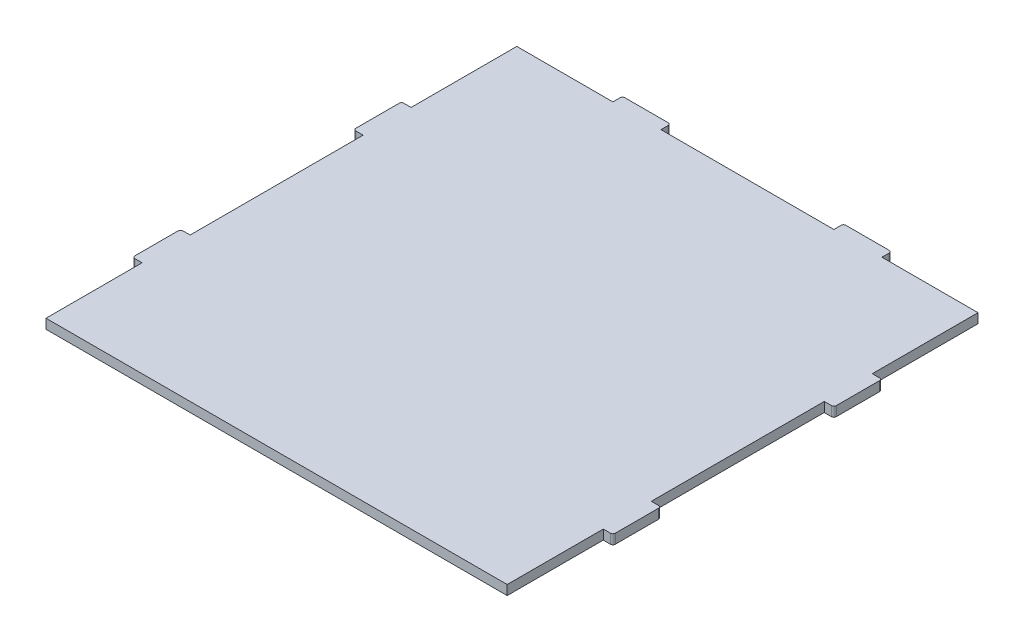
from build123d import *

# Parameters (mm, degrees)
SKETCH1_W           = 96
SKETCH1_H           = 2
BOSS_EXTRUDE1_DEPTH = 98
SKETCH2_W           = 10
SKETCH2_H           = 2
BOSS_EXTRUDE2_DEPTH = 2
SKETCH3_W           = 10
SKETCH3_H           = 2
BOSS_EXTRUDE3_DEPTH = 2
SKETCH4_W           = 10
SKETCH4_H           = 2
BOSS_EXTRUDE4_DEPTH = 2
FILLET1_R           = 0.5


with BuildPart() as part:
    # Sketch1 → Boss-Extrude1 (new body)
    with BuildSketch(Plane.XY):
        with Locations((0, 49)):
            Rectangle(SKETCH1_W, SKETCH1_H)
    extrude(amount=BOSS_EXTRUDE1_DEPTH)

    # Sketch2 → Boss-Extrude2 (add)
    with BuildSketch(Plane(origin=(0, 0, 0), x_dir=(-1, 0, 0), z_dir=(0, 0, -1))):
        with Locations((-23, 49)):
            Rectangle(SKETCH2_W, SKETCH2_H)
    boss_extrude2 = extrude(amount=BOSS_EXTRUDE2_DEPTH)

    # Mirror1: Boss-Extrude2 across plane
    add(boss_extrude2.mirror(Plane(origin=(0, 0, 0), x_dir=(0, 0, 1), z_dir=(1, 0, 0))))

    # Sketch3 → Boss-Extrude3 (add)
    with BuildSketch(Plane.ZY.offset(48)):
        with Locations((73, 49)):
            Rectangle(SKETCH3_W, SKETCH3_H)
    boss_extrude3 = extrude(amount=BOSS_EXTRUDE3_DEPTH)

    # Mirror2: Boss-Extrude3 across plane
    add(boss_extrude3.mirror(Plane.XY.offset(50)))

    # Sketch4 → Boss-Extrude4 (add)
    with BuildSketch(Plane(origin=(48, 0, 0), x_dir=(0, 0, -1), z_dir=(1, 0, 0))):
        with Locations((-73, 49)):
            Rectangle(SKETCH4_W, SKETCH4_H)
    boss_extrude4 = extrude(amount=BOSS_EXTRUDE4_DEPTH)

    # Mirror3: Boss-Extrude4 across plane
    add(boss_extrude4.mirror(Plane.XY.offset(50)))

    # Fillet1
    fillet1_edges = [part.edges().sort_by_distance(p)[0] for p in [
        (18, 49, -2),
        (28, 49, -2),
        (-28, 49, -2),
        (-18, 49, -2),
        (-50, 49, 68),
        (-50, 49, 78),
        (-50, 49, 22),
        (-50, 49, 32),
        (50, 49, 78),
        (50, 49, 68),
        (50, 49, 32),
        (50, 49, 22),
    ]]
    fillet(fillet1_edges, radius=FILLET1_R)


solid = part.part
